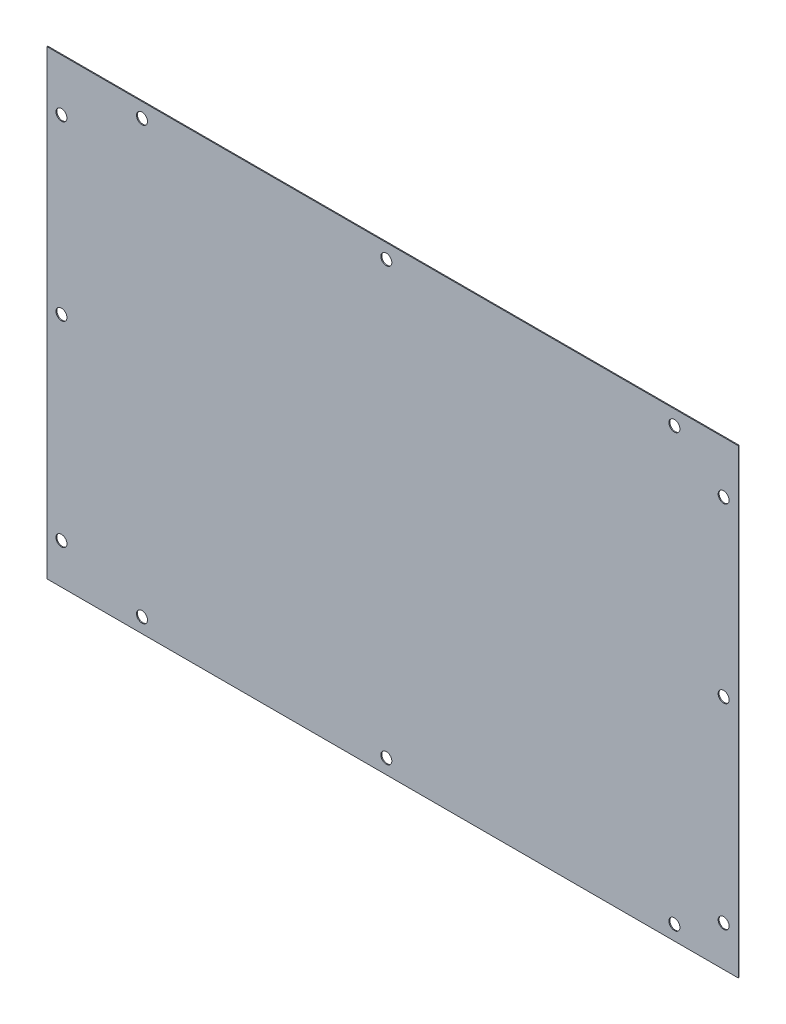
from build123d import *

# Parameters (mm, degrees)
CROQUIS1_W              = 600
CROQUIS1_H              = 400
CROQUIS1_R              = 4.7625
SALIENTE_EXTRUIR1_DEPTH = 0.79375


with BuildPart() as part:
    # Croquis1 → Saliente-Extruir1 (new body)
    with BuildSketch(Plane.XY):
        with Locations((300, 200)):
            Rectangle(CROQUIS1_W, CROQUIS1_H)
        with Locations((82.591965889, 387.3)):
            Circle(CROQUIS1_R, mode=Mode.SUBTRACT)
        with Locations((294.6, 387.3)):
            Circle(CROQUIS1_R, mode=Mode.SUBTRACT)
        with Locations((544.6, 387.3)):
            Circle(CROQUIS1_R, mode=Mode.SUBTRACT)
        with Locations((12.7, 355)):
            Circle(CROQUIS1_R, mode=Mode.SUBTRACT)
        with Locations((12.7, 205)):
            Circle(CROQUIS1_R, mode=Mode.SUBTRACT)
        with Locations((12.7, 35)):
            Circle(CROQUIS1_R, mode=Mode.SUBTRACT)
        with Locations((82.591965889, 12.7)):
            Circle(CROQUIS1_R, mode=Mode.SUBTRACT)
        with Locations((294.6, 12.7)):
            Circle(CROQUIS1_R, mode=Mode.SUBTRACT)
        with Locations((544.6, 12.7)):
            Circle(CROQUIS1_R, mode=Mode.SUBTRACT)
        with Locations((587.3, 355)):
            Circle(CROQUIS1_R, mode=Mode.SUBTRACT)
        with Locations((587.3, 205)):
            Circle(CROQUIS1_R, mode=Mode.SUBTRACT)
        with Locations((587.3, 35)):
            Circle(CROQUIS1_R, mode=Mode.SUBTRACT)
    extrude(amount=SALIENTE_EXTRUIR1_DEPTH)


solid = part.part
